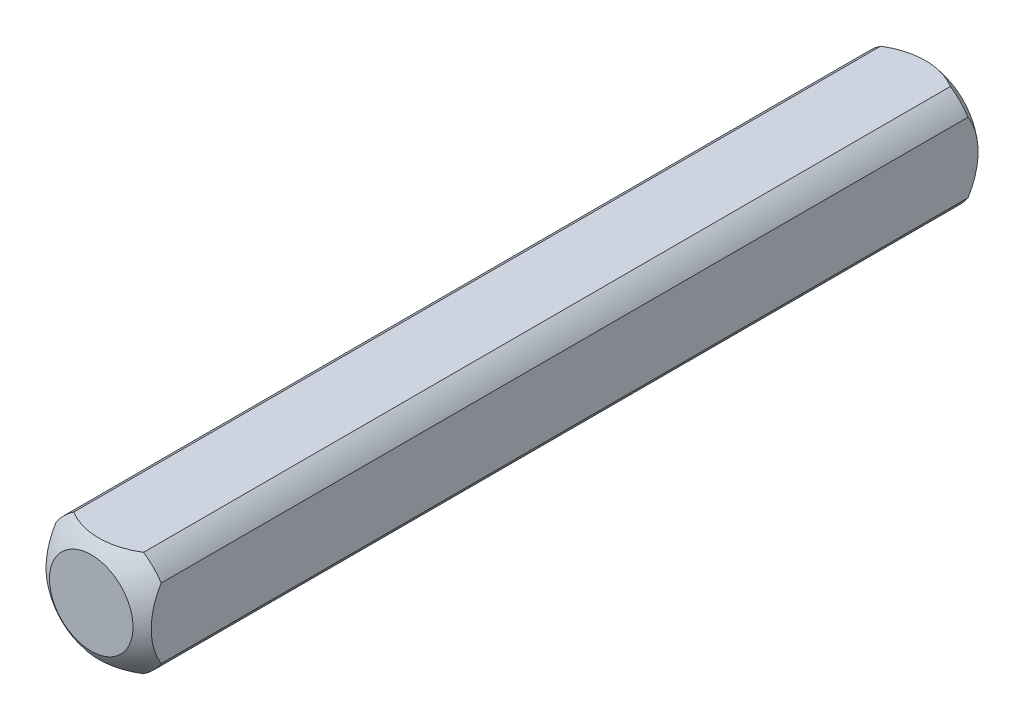
from build123d import *

# Parameters (mm, degrees)
SKETCH1_W           = 6.35
SKETCH1_H           = 6.35
BOSS_EXTRUDE1_DEPTH = 25.4
SKETCH2_OUTSIDE_W   = 13.738
SKETCH2_OUTSIDE_H   = 13.738
SKETCH2_OUTSIDE_R   = 3.81
CUT_EXTRUDE1_DEPTH  = 26.4


with BuildPart() as part:
    # Sketch1 → Boss-Extrude1 (new body)
    with BuildSketch(Plane.XY):
        Rectangle(SKETCH1_W, SKETCH1_H)
    extrude(amount=BOSS_EXTRUDE1_DEPTH)

    # Sketch2 outside → Cut-Extrude1 (cut, through all)
    with BuildSketch(Plane(origin=(0, 0, 0), x_dir=(-1, 0, 0), z_dir=(0, 0, -1))):
        Rectangle(SKETCH2_OUTSIDE_W, SKETCH2_OUTSIDE_H)
        Circle(SKETCH2_OUTSIDE_R, mode=Mode.SUBTRACT)
    extrude(amount=-CUT_EXTRUDE1_DEPTH, mode=Mode.SUBTRACT)

    # Sketch3 → Cut-Revolve1 (revolve, cut)
    with BuildSketch(Plane(origin=(0, 0, 0), x_dir=(1, 0, 0), z_dir=(0, 1, 0))):
        with BuildLine():
            Line((-5.053685963, -3.893335876), (-5.053685963, 5.740530545))
            Line((-5.053685963, 5.740530545), (0, 5.740530545))
            Line((0, 5.740530545), (0, 0.670274551))
            ThreePointArc((0, 0.670274551), (-3.404639553, -0.639469554), (-5.053685963, -3.893335876))
        make_face()
    revolve(axis=Axis((0, 0, 25.4), (0, 0, -1)), mode=Mode.SUBTRACT)

    # Mirror1: part across plane


with BuildPart() as part_1:
    add(part.part)
    add(part.part.mirror(Plane(origin=(0, 0, 25.4), x_dir=(1, 0, 0), z_dir=(0, 0, -1))))


solid = part_1.part
